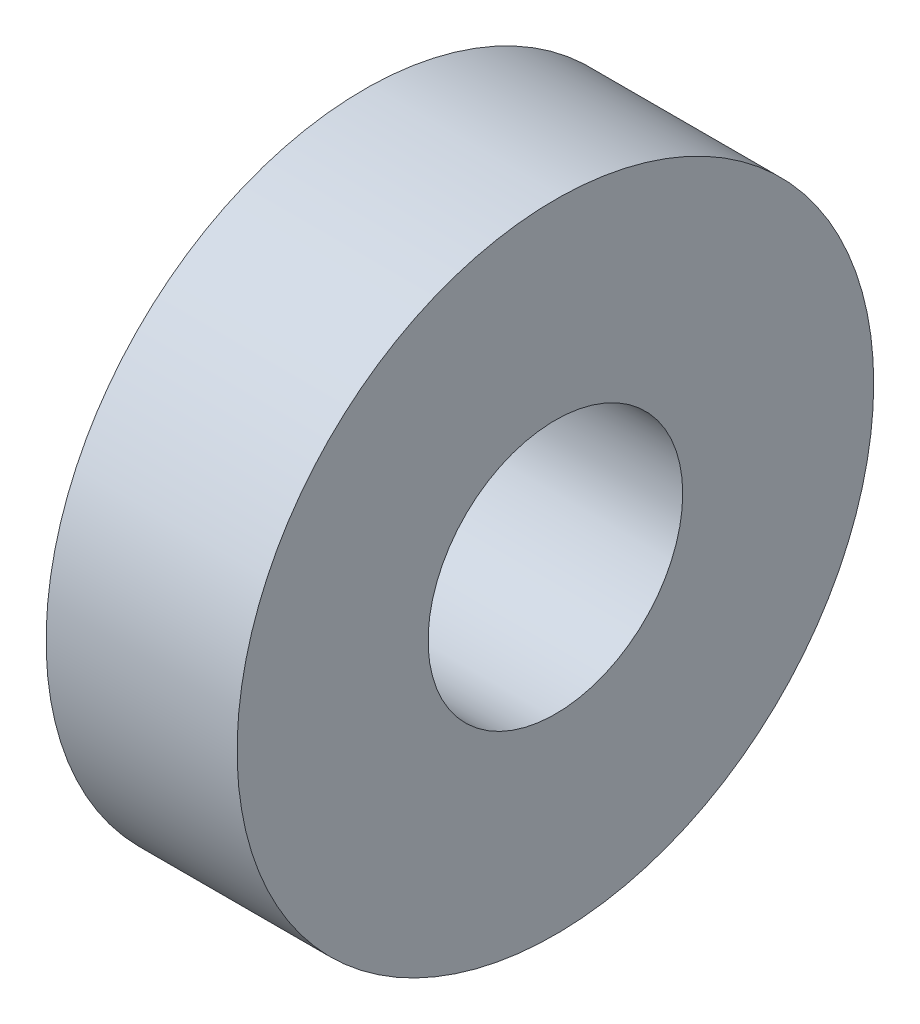
from build123d import *

# Parameters (mm, degrees)
SKETCH1_R           = 5
BOSS_EXTRUDE1_DEPTH = 3
SKETCH2_R           = 2
CUT_EXTRUDE1_DEPTH  = 4


with BuildPart() as part:
    # Sketch1 → Boss-Extrude1 (new body)
    with BuildSketch(Plane(origin=(0, 0, 0), x_dir=(0, 0, -1), z_dir=(1, 0, 0))):
        Circle(SKETCH1_R)
    extrude(amount=BOSS_EXTRUDE1_DEPTH)

    # Sketch2 → Cut-Extrude1 (cut, through all)
    with BuildSketch(Plane(origin=(3, 0, 0), x_dir=(0, 0, -1), z_dir=(1, 0, 0))):
        Circle(SKETCH2_R)
    extrude(amount=-CUT_EXTRUDE1_DEPTH, mode=Mode.SUBTRACT)


solid = part.part
